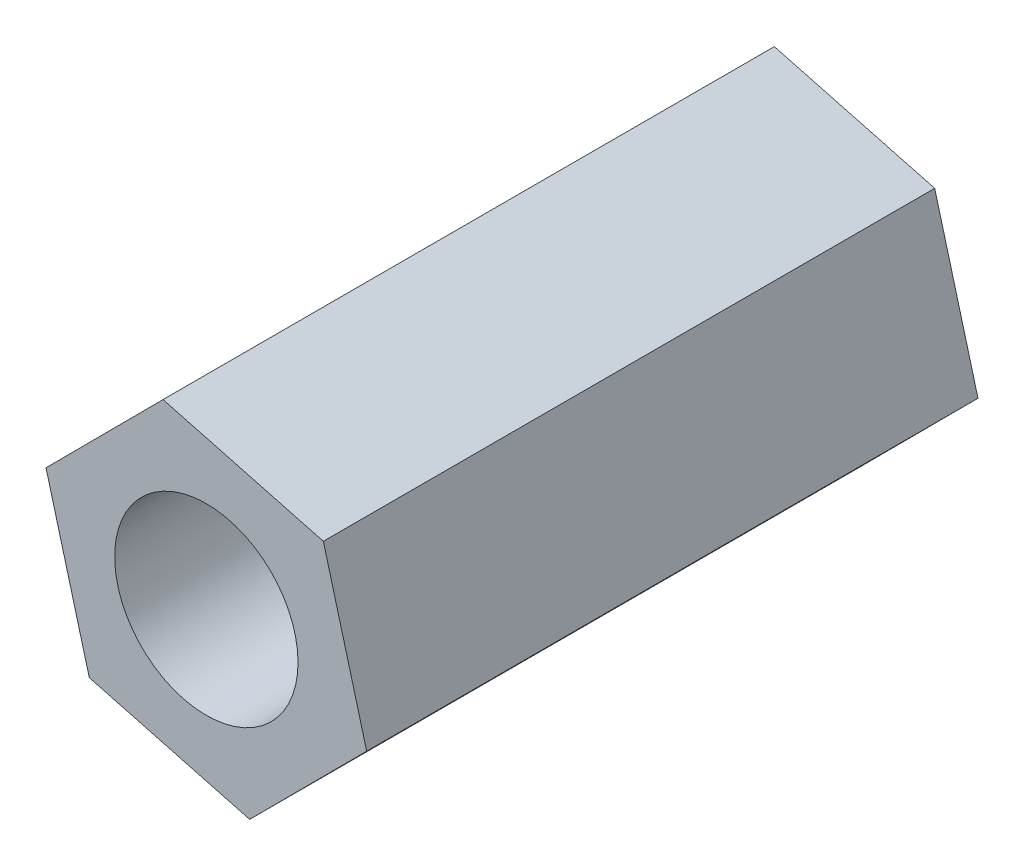
from build123d import *

# Parameters (mm, degrees)
SKETCH1_R           = 1.5
BOSS_EXTRUDE1_DEPTH = 10


with BuildPart() as part:
    # Sketch1 → Boss-Extrude1 (new body)
    with BuildSketch(Plane.XY):
        Polygon((1.91424692, 1.923276387), (-0.708482749, 2.619424656), (-2.62272967, 0.696148269), (-1.91424692, -1.923276387), (0.708482749, -2.619424656), (2.62272967, -0.696148269), align=None)
        Circle(SKETCH1_R, mode=Mode.SUBTRACT)
    extrude(amount=BOSS_EXTRUDE1_DEPTH)


solid = part.part
